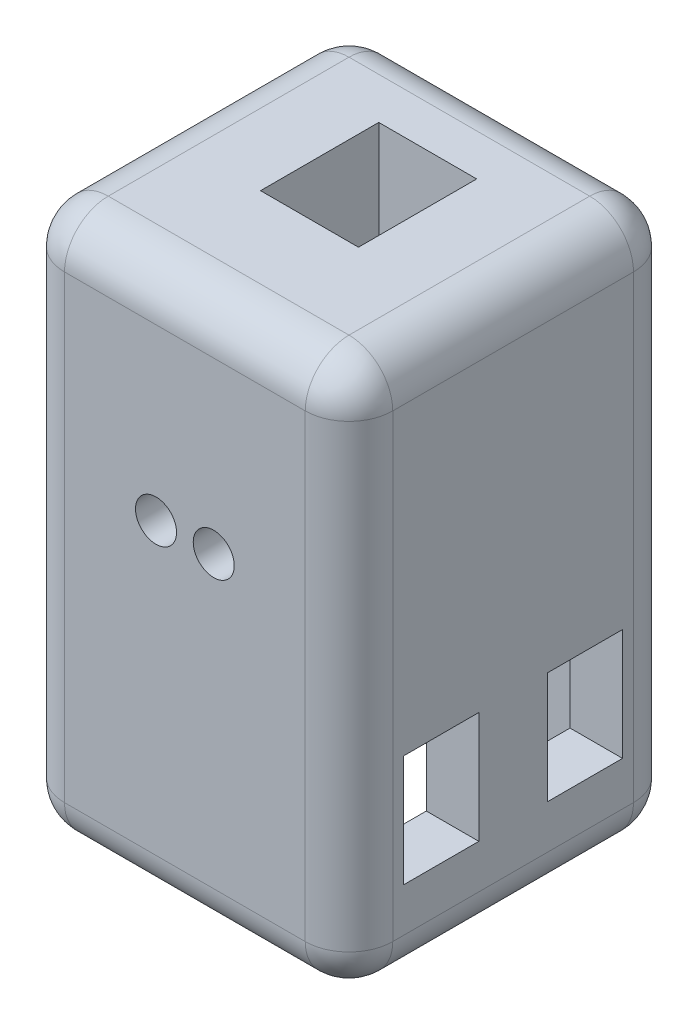
from build123d import *

# Parameters (mm, degrees)
SKETCH1_W               = 38.1
SKETCH1_H               = 38.1
BOSS_EXTRUDE1_DEPTH     = 63.5
SKETCH4_W               = 8.9154
SKETCH4_H               = 152.4
BOSS_EXTRUDE3_DEPTH     = 5.55625
BOSS_EXTRUDE4_DEPTH     = 11.1125
LPATTERN1_COUNT         = 24
LPATTERN1_PITCH         = 6.23316
FILLET1_R               = 0.50038
SKETCH8_W               = 25.908
SKETCH8_H               = 25.908
CUT_EXTRUDE3_DEPTH      = 35.56
SKETCH9_W               = 12.7
SKETCH9_H               = 12.7
CUT_EXTRUDE4_DEPTH      = 6.35
SKETCH10_R              = 2.38125
CUT_EXTRUDE5_DEPTH      = 26.4
CUT_EXTRUDE5_DEPTH_BACK = 13.7
SKETCH11_W              = 8.720666667
SKETCH11_H              = 12.954
CUT_EXTRUDE6_DEPTH      = 39.1
FILLET2_R               = 0.635
FILLET3_R               = 5.08
SKETCH15_W              = 11.3665
SKETCH15_H              = 13.722050523
CUT_EXTRUDE9_DEPTH      = 173.99


with BuildPart() as part:
    # Sketch1 → Boss-Extrude1 (new body)
    with BuildSketch(Plane(origin=(0, 0, 0), x_dir=(1, 0, 0), z_dir=(0, 1, 0))):
        Rectangle(SKETCH1_W, SKETCH1_H)
    extrude(amount=BOSS_EXTRUDE1_DEPTH)

    # Sketch4 → Boss-Extrude3 (add, symmetric)
    with BuildSketch(Plane(origin=(0, 0, 0), x_dir=(0, 0, -1), z_dir=(1, 0, 0))):
        with Locations((0, 139.7)):
            Rectangle(SKETCH4_W, SKETCH4_H)
    extrude(amount=BOSS_EXTRUDE3_DEPTH, both=True)

    # Sketch5 → Boss-Extrude4 (add)
    with BuildSketch(Plane.ZY.offset(5.55625)):
        Polygon((-4.4577, 215.9), (-8.95858, 214.2617), (-8.95858, 212.57514), (-4.4577, 210.93684), align=None)
    boss_extrude4 = extrude(amount=-BOSS_EXTRUDE4_DEPTH)

    # LPattern1: Boss-Extrude4 ×24
    with Locations(*[(0, -i * LPATTERN1_PITCH, 0) for i in range(1, LPATTERN1_COUNT)]):
        add(boss_extrude4)

    # Fillet1
    fillet1_edges = [part.edges().sort_by_distance(p)[0] for p in [
        (0, 170.62958, -8.95858),
        (0, 168.94302, -8.95858),
        (0, 167.30472, -4.4577),
        (0, 172.26788, -4.4577),
        (0, 164.39642, -8.95858),
        (0, 162.70986, -8.95858),
        (0, 161.07156, -4.4577),
        (0, 166.03472, -4.4577),
        (0, 158.16326, -8.95858),
        (0, 156.4767, -8.95858),
        (0, 154.8384, -4.4577),
        (0, 159.80156, -4.4577),
        (0, 151.9301, -8.95858),
        (0, 150.24354, -8.95858),
        (0, 148.60524, -4.4577),
        (0, 153.5684, -4.4577),
        (0, 145.69694, -8.95858),
        (0, 144.01038, -8.95858),
        (0, 142.37208, -4.4577),
        (0, 147.33524, -4.4577),
        (0, 214.2617, -8.95858),
        (0, 212.57514, -8.95858),
        (0, 210.93684, -4.4577),
        (0, 208.02854, -8.95858),
        (0, 206.34198, -8.95858),
        (0, 204.70368, -4.4577),
        (0, 209.66684, -4.4577),
        (0, 201.79538, -8.95858),
        (0, 200.10882, -8.95858),
        (0, 198.47052, -4.4577),
        (0, 203.43368, -4.4577),
        (0, 195.56222, -8.95858),
        (0, 193.87566, -8.95858),
        (0, 192.23736, -4.4577),
        (0, 197.20052, -4.4577),
        (0, 189.32906, -8.95858),
        (0, 187.6425, -8.95858),
        (0, 186.0042, -4.4577),
        (0, 190.96736, -4.4577),
        (0, 183.0959, -8.95858),
        (0, 181.40934, -8.95858),
        (0, 179.77104, -4.4577),
        (0, 184.7342, -4.4577),
        (0, 176.86274, -8.95858),
        (0, 175.17618, -8.95858),
        (0, 173.53788, -4.4577),
        (0, 178.50104, -4.4577),
    ]]
    fillet(fillet1_edges, radius=FILLET1_R)

    # Sketch8 → Cut-Extrude3 (cut)
    with BuildSketch(Plane.XZ):
        Rectangle(SKETCH8_W, SKETCH8_H)
    extrude(amount=-CUT_EXTRUDE3_DEPTH, mode=Mode.SUBTRACT)

    # Sketch9 → Cut-Extrude4 (cut)
    with BuildSketch(Plane.XZ.offset(-35.56)):
        Rectangle(SKETCH9_W, SKETCH9_H)
    extrude(amount=-CUT_EXTRUDE4_DEPTH, mode=Mode.SUBTRACT)

    # Sketch10 → Cut-Extrude5 (cut, two sides)
    with BuildSketch(Plane(origin=(0, 0, 6.35), x_dir=(-1, 0, 0), z_dir=(0, 0, -1))) as cut_extrude5_sk:
        with Locations((-3.35, 38.735)):
            Circle(SKETCH10_R)
        with Locations((3.35, 38.735)):
            Circle(SKETCH10_R)
    extrude(amount=CUT_EXTRUDE5_DEPTH, mode=Mode.SUBTRACT)
    extrude(cut_extrude5_sk.sketch, amount=-CUT_EXTRUDE5_DEPTH_BACK, mode=Mode.SUBTRACT)

    # Sketch11 → Cut-Extrude6 (cut, through all)
    with BuildSketch(Plane.ZY.offset(19.05)):
        with Locations((-8.339666667, 16.637)):
            Rectangle(SKETCH11_W, SKETCH11_H)
        with Locations((8.339666667, 16.637)):
            Rectangle(SKETCH11_W, SKETCH11_H)
    extrude(amount=-CUT_EXTRUDE6_DEPTH, mode=Mode.SUBTRACT)

    # Fillet2
    fillet2_edges = [part.edges().sort_by_distance(p)[0] for p in [
        (5.73125, 38.735, -6.35),
        (5.73125, 38.735, 6.35),
        (-0.96875, 38.735, -6.35),
        (-0.96875, 38.735, 6.35),
    ]]
    fillet(fillet2_edges, radius=FILLET2_R)

    # Fillet3
    fillet3_edges = [part.edges().sort_by_distance(p)[0] for p in [
        (-19.05, 63.5, 0),
        (0, 63.5, 19.05),
        (19.05, 63.5, 0),
        (0, 0, 19.05),
        (-19.05, 0, 0),
        (0, 0, -19.05),
        (19.05, 0, 0),
        (0, 63.5, -19.05),
        (19.05, 31.75, 19.05),
        (-19.05, 31.75, 19.05),
        (-19.05, 31.75, -19.05),
        (19.05, 31.75, -19.05),
    ]]
    fillet(fillet3_edges, radius=FILLET3_R)

    # Sketch15 → Cut-Extrude9 (cut)
    with BuildSketch(Plane(origin=(0, 215.9, 0), x_dir=(1, 0, 0), z_dir=(0, 1, 0))):
        with Locations((0, 2.276325261)):
            Rectangle(SKETCH15_W, SKETCH15_H)
    extrude(amount=-CUT_EXTRUDE9_DEPTH, mode=Mode.SUBTRACT)


solid = part.part
